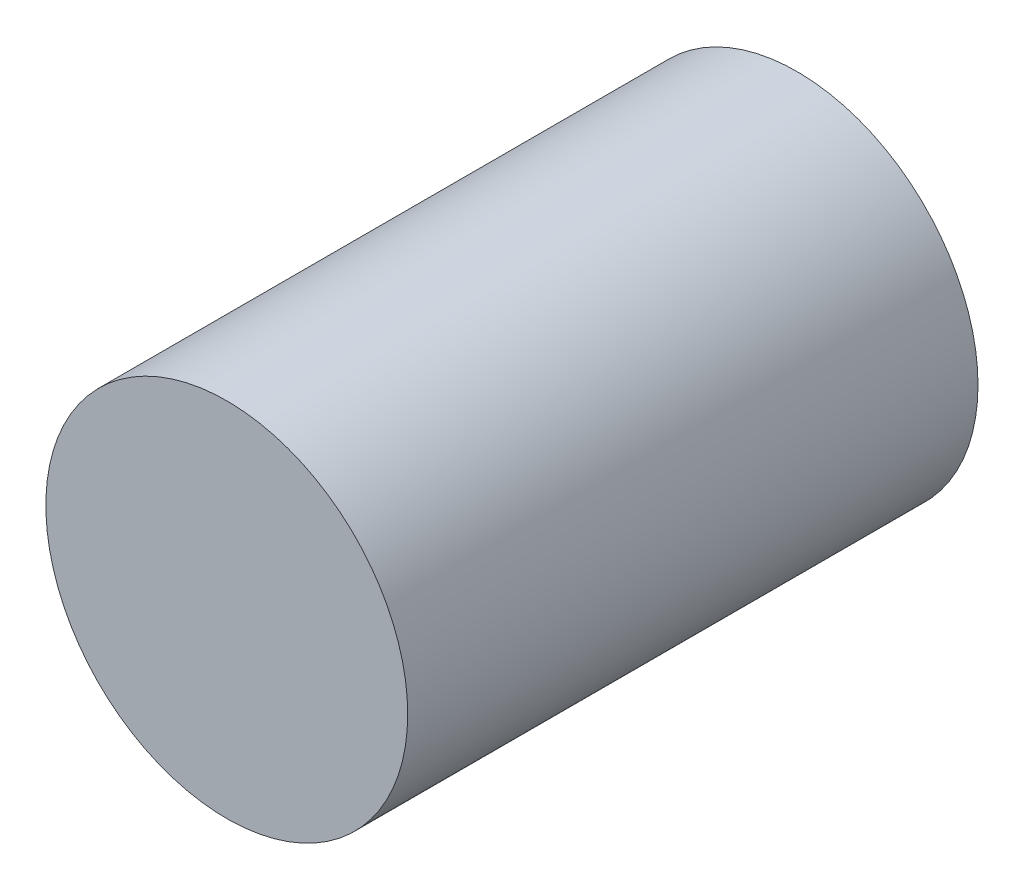
from build123d import *

# Parameters (mm, degrees)
SKETCH_1_R      = 7.9
EXTRUDE_1_DEPTH = 24.9


with BuildPart() as part:
    # Эскиз1 → Бобышка-Вытянуть1 (new body)
    with BuildSketch(Plane.XY):
        with Locations((0, 62)):
            Circle(SKETCH_1_R)
    extrude(amount=-EXTRUDE_1_DEPTH)


solid = part.part
